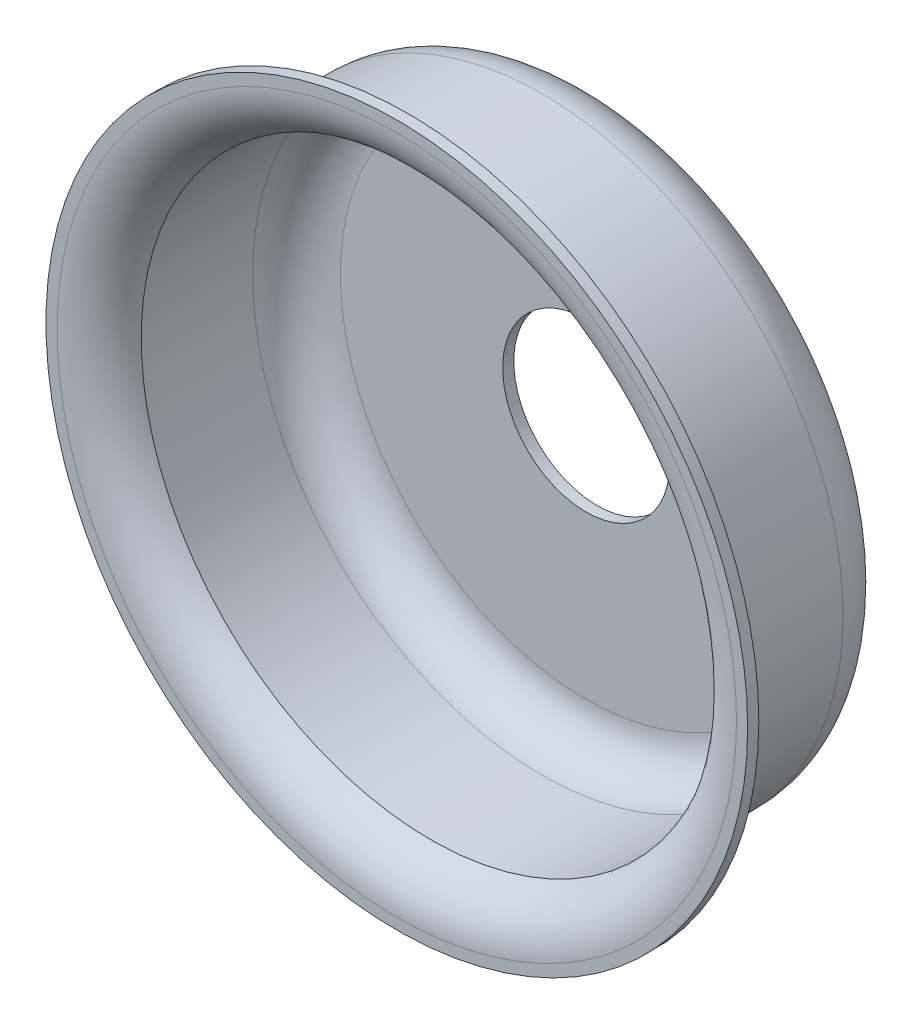
from build123d import *


with BuildPart() as part:
    # Sketch1 → Revolve1 (revolve)
    with BuildSketch(Plane(origin=(0, 0, 0), x_dir=(0, 0, -1), z_dir=(1, 0, 0))):
        with BuildLine():
            Line((0, 8.001), (0, 7.747))
            ThreePointArc((0, 7.747), (0.21198872, 7.056541514), (0.774908178, 6.604))
            Line((0.774908178, 6.604), (3.31799946, 6.604))
            ThreePointArc((3.31799946, 6.604), (4.025106623, 6.311106623), (4.318, 5.60399946))
            Line((4.318, 5.60399946), (4.318, 1.905))
            Line((4.318, 1.905), (4.572, 1.905))
            Line((4.572, 1.905), (4.572, 5.60399946))
            ThreePointArc((4.572, 5.60399946), (4.204711745, 6.490711745), (3.31799946, 6.858))
            Line((3.31799946, 6.858), (0.774908178, 6.858))
            ThreePointArc((0.774908178, 6.858), (0.393818958, 7.231814031), (0.254, 7.747))
            Line((0.254, 7.747), (0.254, 8.001))
            Line((0.254, 8.001), (0, 8.001))
        make_face()
    revolve(axis=Axis((0, 0, 11.444404328), (0, 0, -1)))


solid = part.part
